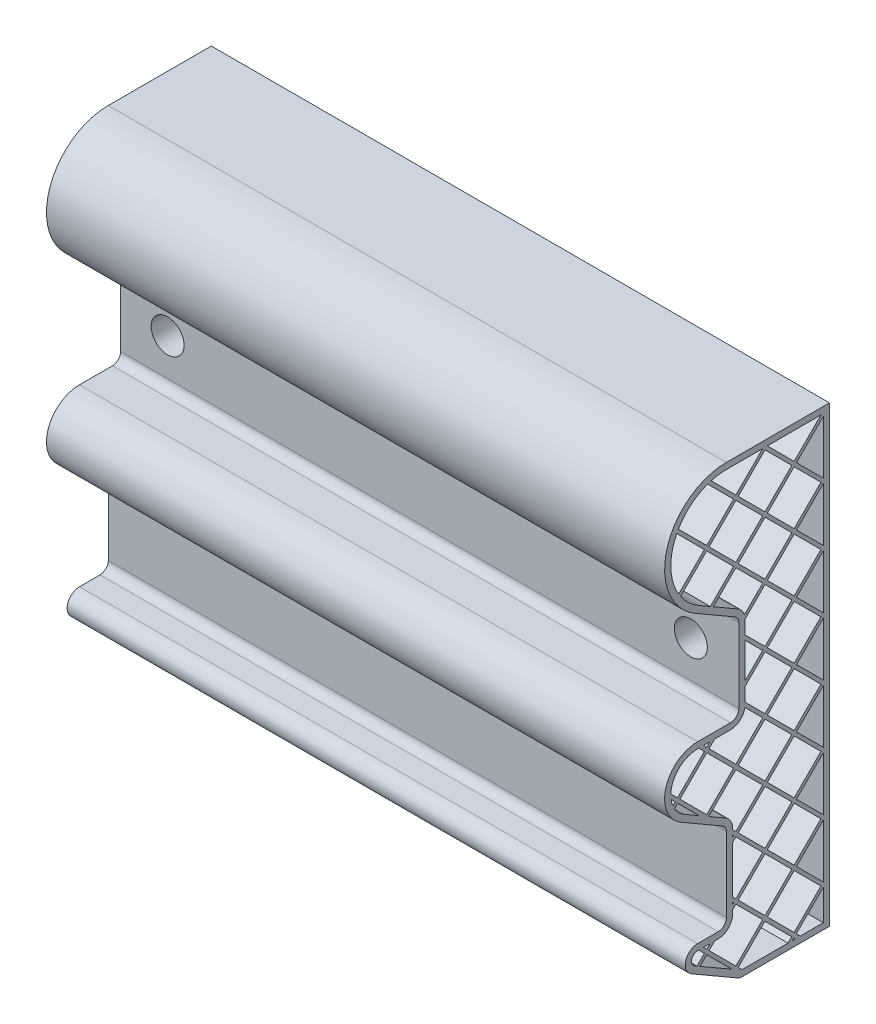
from build123d import *

# Parameters (mm, degrees)
SALIENTE_EXTRUIR1_DEPTH = 150
CORTAR_EXTRUIR1_DEPTH   = 151
CROQUIS6_R              = 5
SALIENTE_EXTRUIR2_DEPTH = 22
CROQUIS6_3_R            = 5
SALIENTE_EXTRUIR3_DEPTH = 22
CROQUIS7_R              = 2.5
CROQUIS7_R_2            = 2.567013522
CORTAR_EXTRUIR2_DEPTH   = 22
CROQUIS8_R              = 4
CORTAR_EXTRUIR3_DEPTH   = 7
CORTAR_EXTRUIR4_DEPTH   = 0.5


with BuildPart() as part:
    # Croquis1 → Saliente-Extruir1 (new body)
    with BuildSketch(Plane(origin=(0, 0, 0), x_dir=(0, 0, -1), z_dir=(1, 0, 0))):
        with BuildLine():
            Line((0, 0), (-21.253866082, 0))
            ThreePointArc((-21.253866082, 0), (-21.771504172, 0.068148347), (-22.253866082, 0.267949192))
            Line((-22.253866082, 0.267949192), (-33.5, 6.760907637))
            ThreePointArc((-33.5, 6.760907637), (-34.897777479, 10.135440984), (-32, 12.358983849))
            Line((-32, 12.358983849), (-27, 12.358983849))
            ThreePointArc((-27, 12.358983849), (-25.585786438, 12.944770286), (-25, 14.358983849))
            Line((-25, 14.358983849), (-25, 32.358983849))
            ThreePointArc((-25, 32.358983849), (-25.267949192, 33.358983849), (-26, 34.091034656))
            Line((-26, 34.091034656), (-36, 39.864537348))
            ThreePointArc((-36, 39.864537348), (-39.72740661, 48.863292939), (-32, 54.792740578))
            Line((-32, 54.792740578), (-24, 54.792740578))
            ThreePointArc((-24, 54.792740578), (-22.585786438, 55.378527016), (-22, 56.792740578))
            Line((-22, 56.792740578), (-22, 74.792740578))
            ThreePointArc((-22, 74.792740578), (-22.267949192, 75.792740578), (-23, 76.524791386))
            Line((-23, 76.524791386), (-32.5, 82.009618943))
            ThreePointArc((-32.5, 82.009618943), (-39.488887394, 98.882285677), (-25, 110))
            Line((-25, 110), (0, 110))
            Line((0, 110), (0, 0))
        make_face()
    extrude(amount=SALIENTE_EXTRUIR1_DEPTH)

    # Croquis5 → Cortar-Extruir1 (cut, through all)
    with BuildSketch(Plane(origin=(150, 0, 0), x_dir=(0, 0, -1), z_dir=(1, 0, 0))):
        Polygon((-31.427332912, 7.296303544), (-23.652281634, 2.807375595), (-29.784271247, 8.939365209), align=None)
        with BuildLine():
            Line((-31.703889887, 10.858983849), (-32, 10.858983849))
            ThreePointArc((-32, 10.858983849), (-33.448888739, 9.747212416), (-32.75, 8.059945743))
            Line((-32.75, 8.059945743), (-32.14459329, 7.710414016))
            Line((-32.14459329, 7.710414016), (-30.349956672, 9.505050634))
            Line((-30.349956672, 9.505050634), (-31.703889887, 10.858983849))
        make_face()
        Polygon((-28.996023458, 10.858983849), (-30.572519037, 10.858983849), (-29.784271247, 10.070736059), align=None)
        Polygon((-10.070736059, 1.5), (-9.171921728, 2.398814331), (-15.677304115, 8.904196718), (-22.147518011, 2.433982822), (-21.213535189, 1.5), align=None)
        with BuildLine():
            Line((-22.713203436, 2.999668247), (-16.207821049, 9.505050634))
            Line((-16.207821049, 9.505050634), (-22.713203436, 16.010433021))
            Line((-22.713203436, 16.010433021), (-23.5, 15.223636456))
            Line((-23.5, 15.223636456), (-23.5, 14.358983849))
            ThreePointArc((-23.5, 14.358983849), (-24.525126266, 11.884110114), (-27, 10.858983849))
            Line((-27, 10.858983849), (-27.864652608, 10.858983849))
            Line((-27.864652608, 10.858983849), (-29.218585823, 9.505050634))
            Line((-29.218585823, 9.505050634), (-22.713203436, 2.999668247))
        make_face()
        Polygon((-7.071399565, 1.5), (-8.049919447, 2.478519882), (-1.5, 8.939365209), (-1.5, 1.5), align=None)
        Polygon((-23.5, 16.355007306), (-23.278888861, 16.576118446), (-23.5, 16.795163138), align=None)
        Polygon((-2.065685425, 9.505050634), (-8.571067812, 16.010433021), (-15.076450199, 9.505050634), (-8.571067812, 2.999668247), align=None)
        Polygon((-1.5, 10.070736059), (-8.005382387, 16.576118446), (-1.5, 23.081500833), align=None)
        Polygon((-23.5, 29.36577208), (-22.713203436, 30.152568645), (-16.207821049, 23.647186258), (-22.713203436, 17.141803871), (-23.5, 17.928600435), align=None)
        Polygon((-23.5, 30.49714293), (-23.278888861, 30.718254069), (-23.5, 30.939365209), align=None)
        Polygon((-2.065685425, 23.647186258), (-8.571067812, 30.152568645), (-15.076450199, 23.647186258), (-8.571067812, 17.141803871), align=None)
        Polygon((-1.5, 24.212871683), (-8.005382387, 30.718254069), (-1.5, 37.223636456), align=None)
        Polygon((-2.065685425, 37.789321881), (-8.571067812, 44.294704268), (-15.076450199, 37.789321881), (-8.571067812, 31.283939494), align=None)
        Polygon((-1.5, 38.355007306), (-8.005382387, 44.860389693), (-1.5, 51.36577208), align=None)
        Polygon((-29.784271247, 38.355007306), (-23.278888861, 44.860389693), (-29.784271247, 51.36577208), (-36.289653634, 44.860389693), align=None)
        with BuildLine():
            Line((-29.218585823, 37.789321881), (-22.713203436, 44.294704268))
            Line((-22.713203436, 44.294704268), (-16.207821049, 37.789321881))
            Line((-16.207821049, 37.789321881), (-22.713203436, 31.283939494))
            Line((-22.713203436, 31.283939494), (-23.5, 32.070736059))
            Line((-23.5, 32.070736059), (-23.5, 32.358983849))
            ThreePointArc((-23.5, 32.358983849), (-23.968911087, 34.108983849), (-25.25, 35.390072762))
            Line((-25.25, 35.390072762), (-28.963090506, 37.533826565))
            Line((-28.963090506, 37.533826565), (-29.218585823, 37.789321881))
        make_face()
        Polygon((-1.5, 52.49714293), (-8.005382387, 59.002525317), (-1.5, 65.507907704), align=None)
        Polygon((-2.065685425, 51.931457505), (-8.571067812, 58.436839892), (-15.076450199, 51.931457505), (-8.571067812, 45.426075118), align=None)
        with BuildLine():
            Line((-37.621148526, 43.528894802), (-36.855339059, 44.294704268))
            Line((-36.855339059, 44.294704268), (-31.639942678, 39.079307887))
            Line((-31.639942678, 39.079307887), (-35.25, 41.163575454))
            ThreePointArc((-35.25, 41.163575454), (-36.590534059, 42.190893443), (-37.621148526, 43.528894802))
        make_face()
        with BuildLine():
            Line((-37.996664295, 44.284749882), (-37.421024484, 44.860389693))
            Line((-37.421024484, 44.860389693), (-38.434760865, 45.874126074))
            ThreePointArc((-38.434760865, 45.874126074), (-38.266307689, 45.065491913), (-37.996664295, 44.284749882))
        make_face()
        Polygon((-20.5, 74.792178951), (-15.642135624, 79.650043328), (-9.136753237, 73.144660941), (-15.642135624, 66.639278554), (-20.5, 71.49714293), align=None)
        with BuildLine():
            Line((-20.642449535, 75.781100266), (-16.207821049, 80.215728753))
            Line((-16.207821049, 80.215728753), (-22.713203436, 86.721111139))
            Line((-22.713203436, 86.721111139), (-28.184309751, 81.250004824))
            Line((-28.184309751, 81.250004824), (-22.25, 77.823829492))
            ThreePointArc((-22.25, 77.823829492), (-21.249553925, 76.957237377), (-20.642449535, 75.781100266))
        make_face()
        Polygon((-1.5, 107.934314575), (-8.005382387, 101.428932188), (-1.5, 94.923549801), align=None)
        Polygon((-2.065685425, 108.5), (-8.571067812, 101.994617613), (-15.076450199, 108.5), align=None)
        Polygon((-15.642135624, 107.934314575), (-9.136753237, 101.428932188), (-15.642135624, 94.923549801), (-22.147518011, 101.428932188), align=None)
        with BuildLine():
            Line((-36.165178282, 87.411271917), (-29.784271247, 93.792178951))
            Line((-29.784271247, 93.792178951), (-23.278888861, 87.286796564))
            Line((-23.278888861, 87.286796564), (-28.901570129, 81.664115296))
            Line((-28.901570129, 81.664115296), (-31.75, 83.308657049))
            ThreePointArc((-31.75, 83.308657049), (-34.189464914, 85.110422932), (-36.165178282, 87.411271917))
        make_face()
        with BuildLine():
            Line((-36.605078302, 88.102742747), (-30.349956672, 94.357864376))
            Line((-30.349956672, 94.357864376), (-37.059638564, 101.067546268))
            ThreePointArc((-37.059638564, 101.067546268), (-38.491709998, 94.526965818), (-36.605078302, 88.102742747))
        make_face()
        with BuildLine():
            Line((-36.661739101, 101.801017655), (-29.784271247, 94.923549801))
            Line((-29.784271247, 94.923549801), (-23.278888861, 101.428932188))
            Line((-23.278888861, 101.428932188), (-29.557428651, 107.707471979))
            ThreePointArc((-29.557428651, 107.707471979), (-33.630579431, 105.380900668), (-36.661739101, 101.801017655))
        make_face()
        with BuildLine():
            Line((-28.701285342, 107.98269952), (-22.713203436, 101.994617613))
            Line((-22.713203436, 101.994617613), (-16.207821049, 108.5))
            Line((-16.207821049, 108.5), (-25, 108.5))
            ThreePointArc((-25, 108.5), (-26.868630044, 108.37004943), (-28.701285342, 107.98269952))
        make_face()
        Polygon((-22.713203436, 100.863246763), (-16.207821049, 94.357864376), (-22.713203436, 87.852481989), (-29.218585823, 94.357864376), align=None)
        Polygon((-15.076450199, 94.357864376), (-8.571067812, 87.852481989), (-2.065685425, 94.357864376), (-8.571067812, 100.863246763), align=None)
        Polygon((-15.642135624, 93.792178951), (-22.147518011, 87.286796564), (-15.642135624, 80.781414177), (-9.136753237, 87.286796564), align=None)
        Polygon((-8.005382387, 87.286796564), (-1.5, 80.781414177), (-1.5, 93.792178951), align=None)
        Polygon((-8.571067812, 86.721111139), (-2.065685425, 80.215728753), (-8.571067812, 73.710346366), (-15.076450199, 80.215728753), align=None)
        Polygon((-8.571067812, 72.578975516), (-2.065685425, 66.073593129), (-8.571067812, 59.568210742), (-15.076450199, 66.073593129), align=None)
        Polygon((-8.005382387, 73.144660941), (-1.5, 66.639278554), (-1.5, 79.650043328), align=None)
        Polygon((-16.207821049, 66.073593129), (-20.5, 70.36577208), (-20.5, 61.781414177), align=None)
        Polygon((-9.136753237, 59.002525317), (-15.642135624, 65.507907704), (-20.5, 60.650043328), (-20.5, 57.355007306), (-15.642135624, 52.49714293), align=None)
        with BuildLine():
            Line((-16.207821049, 51.931457505), (-20.540194436, 56.263830892))
            ThreePointArc((-20.540194436, 56.263830892), (-21.719778947, 54.1374455), (-24, 53.292740578))
            Line((-24, 53.292740578), (-27.857302749, 53.292740578))
            Line((-27.857302749, 53.292740578), (-29.218585823, 51.931457505))
            Line((-29.218585823, 51.931457505), (-22.713203436, 45.426075118))
            Line((-22.713203436, 45.426075118), (-16.207821049, 51.931457505))
        make_face()
        Polygon((-29.784271247, 52.49714293), (-28.988673599, 53.292740578), (-30.579868896, 53.292740578), align=None)
        with BuildLine():
            Line((-30.349956672, 51.931457505), (-31.711239746, 53.292740578))
            Line((-31.711239746, 53.292740578), (-32, 53.292740578))
            ThreePointArc((-32, 53.292740578), (-36.498895226, 51.484216012), (-38.494294287, 47.065030346))
            Line((-38.494294287, 47.065030346), (-36.855339059, 45.426075118))
            Line((-36.855339059, 45.426075118), (-30.349956672, 51.931457505))
        make_face()
        Polygon((-22.147518011, 30.718254069), (-15.642135624, 37.223636456), (-9.136753237, 30.718254069), (-15.642135624, 24.212871683), align=None)
        Polygon((-15.642135624, 38.355007306), (-9.136753237, 44.860389693), (-15.642135624, 51.36577208), (-22.147518011, 44.860389693), align=None)
        Polygon((-9.136753237, 16.576118446), (-15.642135624, 23.081500833), (-22.147518011, 16.576118446), (-15.642135624, 10.070736059), align=None)
        Polygon((-8.654886921, 1.881779524), (-8.273107397, 1.5), (-9.041929948, 1.5), align=None)
    extrude(amount=-CORTAR_EXTRUIR1_DEPTH, mode=Mode.SUBTRACT)

    # Croquis6 → Saliente-Extruir2 (add)
    with BuildSketch(Plane.XY.offset(22)):
        with Locations((11.391749044, 65.792740578)):
            Circle(CROQUIS6_R)
    extrude(amount=-SALIENTE_EXTRUIR2_DEPTH)

    # Croquis6_3 → Saliente-Extruir3 (add)
    with BuildSketch(Plane.XY.offset(22)):
        with Locations((138.359294984, 65.792740578)):
            Circle(CROQUIS6_3_R)
    extrude(amount=-SALIENTE_EXTRUIR3_DEPTH)

    # Croquis7 → Cortar-Extruir2 (cut)
    with BuildSketch(Plane.XY.offset(22)):
        with Locations((11.391749044, 65.792740578)):
            Circle(CROQUIS7_R)
        with Locations((138.359294984, 65.792740578)):
            Circle(CROQUIS7_R_2)
    extrude(amount=-CORTAR_EXTRUIR2_DEPTH, mode=Mode.SUBTRACT)

    # Croquis8 → Cortar-Extruir3 (cut)
    with BuildSketch(Plane.XY.offset(22)):
        with Locations((11.391749044, 65.792740578)):
            Circle(CROQUIS8_R)
        with Locations((138.359294984, 65.792740578)):
            Circle(CROQUIS8_R)
    extrude(amount=-CORTAR_EXTRUIR3_DEPTH, mode=Mode.SUBTRACT)

    # Croquis9 → Cortar-Extruir4 (cut)
    with BuildSketch(Plane(origin=(0, 0, 0), x_dir=(-1, 0, 0), z_dir=(0, 0, -1))):
        Polygon((-146.236552998, 9.933390721), (-145.625976075, 9.933390721), (-143.509309408, 4.929204022), (-141.392642741, 9.933390721), (-140.782065818, 9.933390721), (-143.46860428, 3.583390721), (-143.550014536, 3.583390721), align=None)
        with BuildLine():
            Line((-139.398091459, 7.979544567), (-139.967963254, 7.979544567))
            add(Edge.make_bspline(
                [(-139.967963254, 7.979544567), (-139.964249134, 8.055147464), (-139.9569547, 8.20362954), (-139.922794804, 8.420117199), (-139.873916355, 8.627045191), (-139.804807574, 8.822752035), (-139.71898047, 9.008968156), (-139.616055992, 9.184953899), (-139.494147149, 9.350037913), (-139.35588636, 9.502689814), (-139.205720401, 9.642730121), (-139.04369391, 9.763661776), (-138.873432218, 9.865838123), (-138.69545188, 9.951256947), (-138.507744858, 10.015373525), (-138.31201453, 10.062947071), (-138.107400954, 10.09156987), (-137.967991199, 10.094646509), (-137.897089857, 10.096211234)],
                knots=[0, 0, 0, 0, 0.000226936, 0.000445697, 0.000656417, 0.000864005, 0.001067188, 0.001270734, 0.001474522, 0.00168168, 0.001887816, 0.002089561, 0.002286989, 0.002482721, 0.002680645, 0.002880876, 0.003086317, 0.003298933, 0.003298933, 0.003298933, 0.003298933], degree=3))
            add(Edge.make_bspline(
                [(-137.897089857, 10.096211234), (-137.827461065, 10.094581177), (-137.690642977, 10.091378174), (-137.490959037, 10.063871735), (-137.300863088, 10.020790448), (-137.120726712, 9.960346764), (-136.951987137, 9.879095017), (-136.793376756, 9.781490911), (-136.643007285, 9.66860636), (-136.507649264, 9.535703013), (-136.383356034, 9.393821544), (-136.276127657, 9.242350633), (-136.184300918, 9.085906072), (-136.107760413, 8.923294906), (-136.051415704, 8.75298604), (-136.008638098, 8.577458972), (-135.984458361, 8.394896815), (-135.980747379, 8.271332064), (-135.97886069, 8.208510913)],
                knots=[0, 0, 0, 0, 0.000208804, 0.000410292, 0.000603457, 0.000792922, 0.000978974, 0.001163976, 0.001350969, 0.00154169, 0.001731956, 0.001916203, 0.002097498, 0.002275629, 0.002454231, 0.002634721, 0.00281696, 0.003005431, 0.003005431, 0.003005431, 0.003005431], degree=3))
            add(Edge.make_bspline(
                [(-135.97886069, 8.208510913), (-135.981932753, 8.120068414), (-135.988022968, 7.944735455), (-136.040119051, 7.687079918), (-136.121483435, 7.437446143), (-136.219450068, 7.236537038), (-136.318278645, 7.074641985), (-136.407337409, 6.941348763), (-136.511594995, 6.797828842), (-136.632568841, 6.644562816), (-136.767756481, 6.480350174), (-136.918382406, 6.305290116), (-137.085520723, 6.121191334), (-137.202829717, 5.995451171), (-137.263616299, 5.930295769)],
                knots=[0, 0, 0, 0, 0.0002651, 0.000525547, 0.000785404, 0.001051089, 0.001193761, 0.001354284, 0.001531883, 0.001725783, 0.001939958, 0.002169957, 0.002418529, 0.002685853, 0.002685853, 0.002685853, 0.002685853], degree=3))
            Line((-137.263616299, 5.930295769), (-138.852388334, 4.234672772))
            Line((-138.852388334, 4.234672772), (-135.897450434, 4.234672772))
            Line((-135.897450434, 4.234672772), (-135.897450434, 3.583390721))
            Line((-135.897450434, 3.583390721), (-140.212194023, 3.583390721))
            Line((-140.212194023, 3.583390721), (-137.749533767, 6.211415561))
            add(Edge.make_bspline(
                [(-137.749533767, 6.211415561), (-137.689575458, 6.274005346), (-137.574407817, 6.394227513), (-137.411516571, 6.569746883), (-137.265214406, 6.732578193), (-137.13455428, 6.882413788), (-137.022370634, 7.021445347), (-136.922816728, 7.145170023), (-136.843050584, 7.259024526), (-136.756481223, 7.390996783), (-136.672635857, 7.552127701), (-136.600586297, 7.749038823), (-136.556653643, 7.951743981), (-136.551383442, 8.088726248), (-136.548732485, 8.157629503)],
                knots=[0, 0, 0, 0, 0.000260022, 0.000499448, 0.000718331, 0.000916736, 0.001095736, 0.001254271, 0.001392976, 0.001512588, 0.001727648, 0.001936091, 0.002140165, 0.002346709, 0.002346709, 0.002346709, 0.002346709], degree=3))
            add(Edge.make_bspline(
                [(-136.548732485, 8.157629503), (-136.549885903, 8.200957183), (-136.552159069, 8.28634772), (-136.572220891, 8.411543883), (-136.602538524, 8.532311474), (-136.645982064, 8.649021969), (-136.703325721, 8.760501937), (-136.773127424, 8.86688708), (-136.853663682, 8.96973706), (-136.946829556, 9.066172329), (-137.049176171, 9.154493945), (-137.157297167, 9.232733357), (-137.27168807, 9.298118601), (-137.391866577, 9.351718946), (-137.517497643, 9.393765709), (-137.648824252, 9.42290056), (-137.785483539, 9.441193066), (-137.878798596, 9.443668064), (-137.926346668, 9.444929183)],
                knots=[0, 0, 0, 0, 0.000129903, 0.000256015, 0.000379422, 0.000502993, 0.000628718, 0.000754676, 0.000884205, 0.001020051, 0.00115623, 0.001289314, 0.001419795, 0.001550759, 0.001683503, 0.001816508, 0.001953776, 0.002096386, 0.002096386, 0.002096386, 0.002096386], degree=3))
            add(Edge.make_bspline(
                [(-137.926346668, 9.444929183), (-137.976005179, 9.44363191), (-138.073526295, 9.44108428), (-138.216707969, 9.423263161), (-138.353297879, 9.392518565), (-138.483639617, 9.350469456), (-138.607953723, 9.297023232), (-138.725635632, 9.230453923), (-138.836421159, 9.151018157), (-138.940518566, 9.060956005), (-139.036428928, 8.960684786), (-139.120696831, 8.84890671), (-139.194327828, 8.727662685), (-139.258570295, 8.597279857), (-139.310741333, 8.456575142), (-139.350606905, 8.306048021), (-139.382151613, 8.146352086), (-139.392689929, 8.036070575), (-139.398091459, 7.979544567)],
                knots=[0, 0, 0, 0, 0.000148964, 0.000292541, 0.00043203, 0.000568399, 0.000702856, 0.000837284, 0.000973177, 0.00111115, 0.001249715, 0.001388623, 0.001530208, 0.001674706, 0.001824033, 0.001979555, 0.002141464, 0.002311717, 0.002311717, 0.002311717, 0.002311717], degree=3))
        make_face()
    extrude(amount=-CORTAR_EXTRUIR4_DEPTH, mode=Mode.SUBTRACT)


solid = part.part
